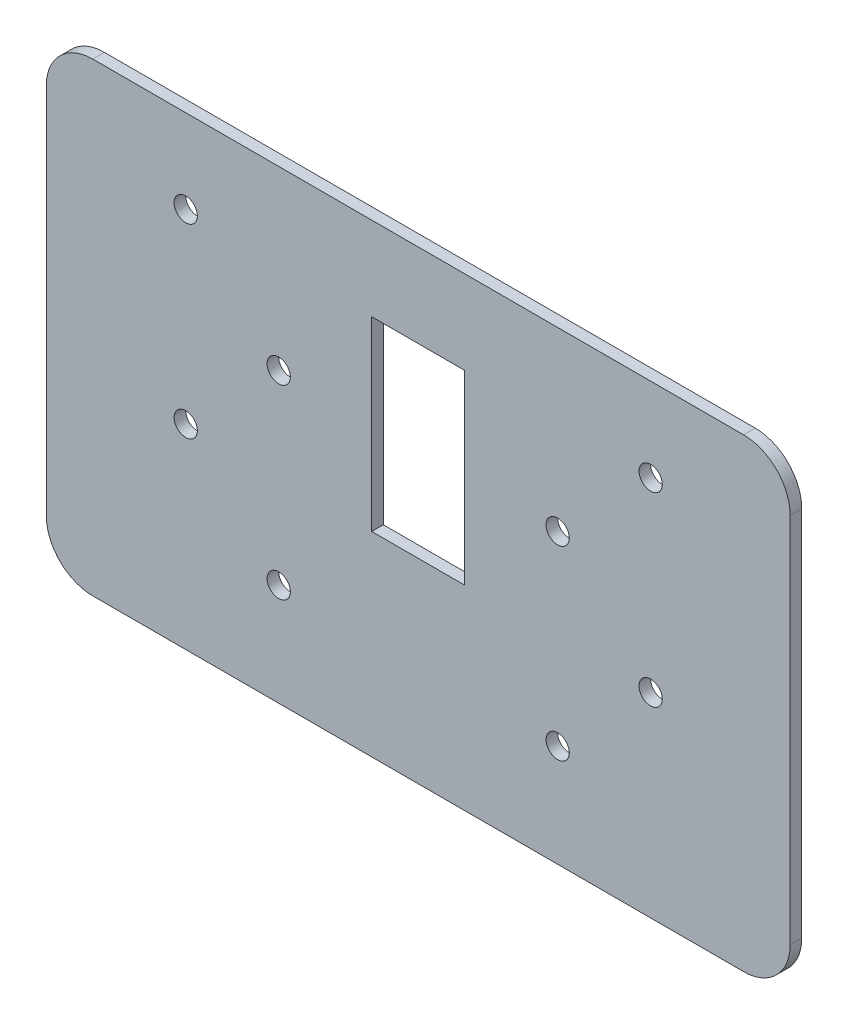
from build123d import *

# Parameters (mm, degrees)
SKETCH1_R           = 3.175
SKETCH1_W           = 25.4
SKETCH1_H           = 50.8
BOSS_EXTRUDE1_DEPTH = 3.175


with BuildPart() as part:
    # Sketch1 → Boss-Extrude1 (new body)
    with BuildSketch(Plane.XY):
        with BuildLine():
            Line((214.219369126, 454.630831078), (392.019369126, 454.630831078))
            ThreePointArc((392.019369126, 454.630831078), (400.999625247, 450.911087199), (404.719369126, 441.930831078))
            Line((404.719369126, 441.930831078), (404.719369126, 340.330831078))
            ThreePointArc((404.719369126, 340.330831078), (400.999625247, 331.350574957), (392.019369126, 327.630831078))
            Line((392.019369126, 327.630831078), (214.219369126, 327.630831078))
            ThreePointArc((214.219369126, 327.630831078), (205.239113005, 331.350574957), (201.519369126, 340.330831078))
            Line((201.519369126, 340.330831078), (201.519369126, 441.930831078))
            ThreePointArc((201.519369126, 441.930831078), (205.239113005, 450.911087199), (214.219369126, 454.630831078))
        make_face()
        with Locations((265.019369126, 406.370831078)):
            Circle(SKETCH1_R, mode=Mode.SUBTRACT)
        with Locations((239.619369126, 431.770831078)):
            Circle(SKETCH1_R, mode=Mode.SUBTRACT)
        with Locations((239.619369126, 380.970831078)):
            Circle(SKETCH1_R, mode=Mode.SUBTRACT)
        with Locations((366.619369126, 380.970831078)):
            Circle(SKETCH1_R, mode=Mode.SUBTRACT)
        with Locations((341.219369126, 406.370831078)):
            Circle(SKETCH1_R, mode=Mode.SUBTRACT)
        with Locations((366.619369126, 431.770831078)):
            Circle(SKETCH1_R, mode=Mode.SUBTRACT)
        with Locations((265.019369126, 355.570831078)):
            Circle(SKETCH1_R, mode=Mode.SUBTRACT)
        with Locations((341.219369126, 355.570831078)):
            Circle(SKETCH1_R, mode=Mode.SUBTRACT)
        with Locations((303.119369126, 406.370831078)):
            Rectangle(SKETCH1_W, SKETCH1_H, mode=Mode.SUBTRACT)
    extrude(amount=BOSS_EXTRUDE1_DEPTH)


solid = part.part
